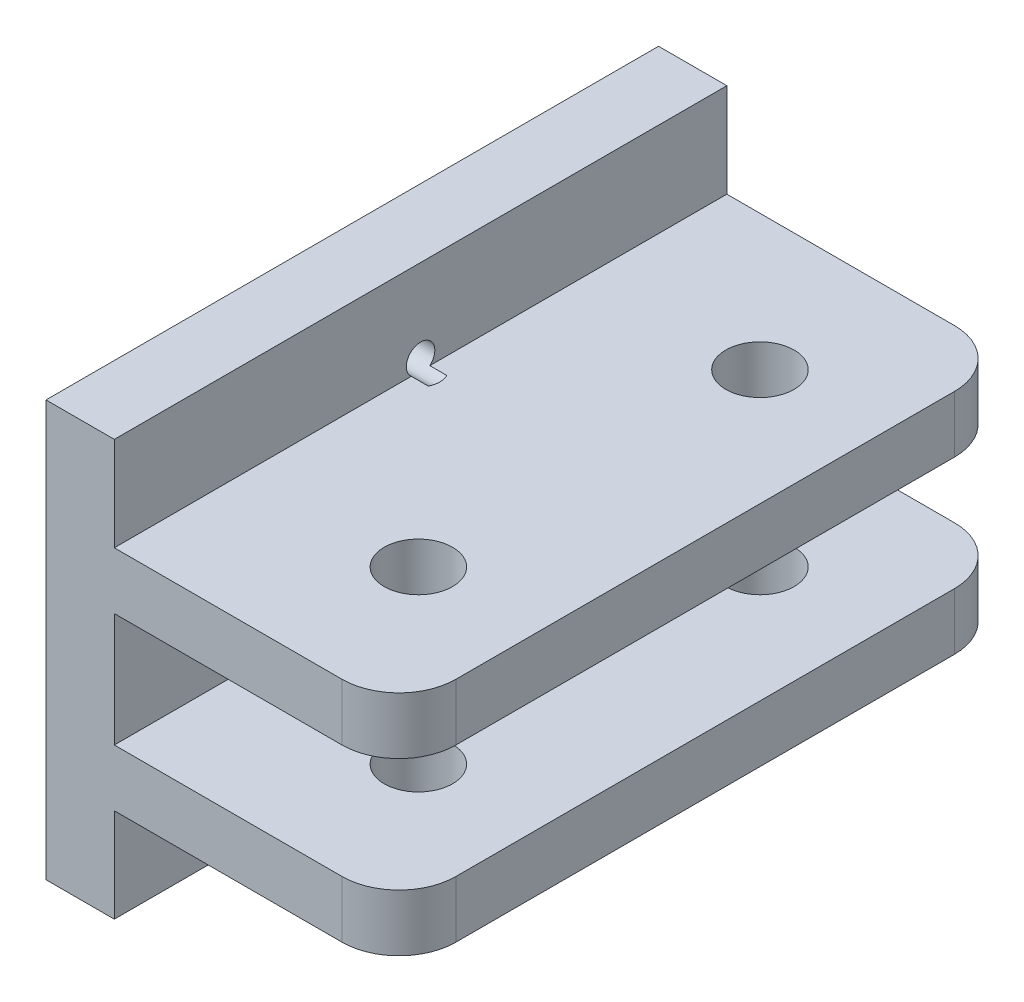
from build123d import *

# Parameters (mm, degrees)
SKETCH_1_W             = 53.8
SKETCH_1_H             = 36.5
EXTRUDE_1_DEPTH        = 6
SKETCH_2_W             = 53.8
SKETCH_2_H             = 20
EXTRUDE_2_DEPTH        = 25
SKETCH_3_W             = 53.8
SKETCH_3_H             = 10
CUT_EXTRUDE_1_DEPTH    = 25
HOLE_WIZARD_M3_1_D     = 2.5
HOLE_WIZARD_M3_1_DEPTH = 7.5
HOLE_WIZARD_M3_1_TIP   = 0.751075774
SKETCH_6_R             = 3
CUT_EXTRUDE_2_DEPTH    = 29.25
FILLET_1_R             = 5


with BuildPart() as part:
    # 草图1 → 凸台-拉伸1 (new body)
    with BuildSketch(Plane(origin=(0, 0, 0), x_dir=(0, 0, -1), z_dir=(1, 0, 0))):
        Rectangle(SKETCH_1_W, SKETCH_1_H)
    extrude(amount=EXTRUDE_1_DEPTH)

    # 草图2 → 凸台-拉伸2 (add)
    with BuildSketch(Plane(origin=(6, 0, 0), x_dir=(0, 0, -1), z_dir=(1, 0, 0))):
        Rectangle(SKETCH_2_W, SKETCH_2_H)
    extrude(amount=EXTRUDE_2_DEPTH)

    # 草图3 → 切除-拉伸1 (cut)
    with BuildSketch(Plane(origin=(31, 0, 0), x_dir=(0, 0, -1), z_dir=(1, 0, 0))):
        Rectangle(SKETCH_3_W, SKETCH_3_H)
    extrude(amount=-CUT_EXTRUDE_1_DEPTH, mode=Mode.SUBTRACT)

    # M3 螺纹孔1
    with Locations(Plane.ZY):
        with Locations((-10.95, 0), (0, 10.95), (0, 0), (0, -10.95), (10.95, 0)):
            Hole(HOLE_WIZARD_M3_1_D / 2, depth=HOLE_WIZARD_M3_1_DEPTH)
            with Locations((0, 0, -(HOLE_WIZARD_M3_1_DEPTH + HOLE_WIZARD_M3_1_TIP / 2))):  # 118° drill point
                Cone(0, HOLE_WIZARD_M3_1_D / 2, HOLE_WIZARD_M3_1_TIP, mode=Mode.SUBTRACT)

    # 草图6 → 切除-拉伸2 (cut, through all)
    with BuildSketch(Plane.XZ.offset(10)):
        with Locations((20.806055882, 15)):
            Circle(SKETCH_6_R)
        with Locations((20.806055882, -15)):
            Circle(SKETCH_6_R)
    extrude(amount=-CUT_EXTRUDE_2_DEPTH, mode=Mode.SUBTRACT)

    # 圆角1
    fillet_1_edges = [part.edges().sort_by_distance(p)[0] for p in [
        (31, -7.5, -26.9),
        (31, 7.5, 26.9),
        (31, 7.5, -26.9),
        (31, -7.5, 26.9),
    ]]
    fillet(fillet_1_edges, radius=FILLET_1_R)


solid = part.part
